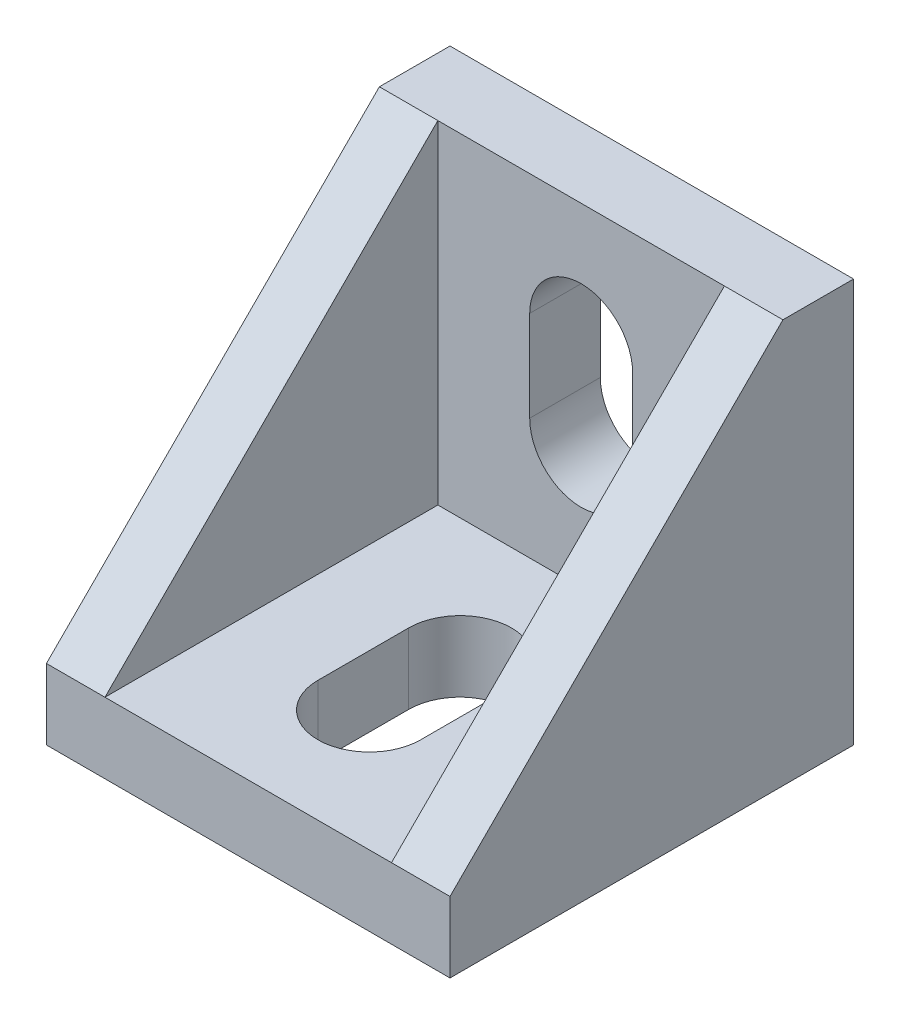
from build123d import *

# Parameters (mm, degrees)
SKETCH1_W          = 20
SKETCH1_H          = 20
EXTRUDE1_DEPTH     = 3.5
SKETCH2_W          = 20
SKETCH2_H          = 3.5
EXTRUDE2_DEPTH     = 16.5
EXTRUDE3_DEPTH     = 2.9
EXTRUDE4_DEPTH     = 2.9
CUT_EXTRUDE1_REACH = 5.5
CUT_EXTRUDE2_REACH = 5.5


with BuildPart() as part:
    # Sketch1 → Extrude1 (new body)
    with BuildSketch(Plane.XY):
        with Locations((10, 10)):
            Rectangle(SKETCH1_W, SKETCH1_H)
    extrude(amount=EXTRUDE1_DEPTH)

    # Sketch2 → Extrude2 (add)
    with BuildSketch(Plane.XY.offset(3.5)):
        with Locations((10, 1.75)):
            Rectangle(SKETCH2_W, SKETCH2_H)
    extrude(amount=EXTRUDE2_DEPTH)

    # Sketch5 → Extrude3 (add)
    with BuildSketch(Plane(origin=(20, 0, 0), x_dir=(0, 0, -1), z_dir=(1, 0, 0))):
        Polygon((-3.5, 20), (-20, 3.5), (-3.5, 3.5), align=None)
    extrude(amount=-EXTRUDE3_DEPTH)

    # Sketch6 → Extrude4 (add)
    with BuildSketch(Plane.ZY):
        Polygon((3.5, 20), (20, 3.5), (3.5, 3.5), align=None)
    extrude(amount=-EXTRUDE4_DEPTH)

    # Sketch7 → Cut-Extrude1 (cut, up to next)
    with BuildSketch(Plane(origin=(0, 3.5, 0), x_dir=(1, 0, 0), z_dir=(0, 1, 0)), mode=Mode.PRIVATE) as cut_extrude1_sk1:
        with BuildLine():
            Line((7.45, -14), (7.45, -9.5))
            ThreePointArc((7.45, -9.5), (10, -6.95), (12.55, -9.5))
            Line((12.55, -9.5), (12.55, -14))
            ThreePointArc((12.55, -14), (10, -16.55), (7.45, -14))
        make_face()
    cut_extrude1_tool1 = extrude(cut_extrude1_sk1.sketch, amount=-CUT_EXTRUDE1_REACH, mode=Mode.PRIVATE) & part.part
    add(cut_extrude1_tool1.solids().sort_by_distance((10, 3.5, 11.75))[0], mode=Mode.SUBTRACT)

    # Sketch8 → Cut-Extrude2 (cut, up to next)
    with BuildSketch(Plane(origin=(0, 0, 3.5), x_dir=(-1, 0, 0), z_dir=(0, 0, 1)), mode=Mode.PRIVATE) as cut_extrude2_sk1:
        with BuildLine():
            Line((-12.55, -14), (-12.55, -9.5))
            ThreePointArc((-12.55, -9.5), (-10, -6.95), (-7.45, -9.5))
            Line((-7.45, -9.5), (-7.45, -14))
            ThreePointArc((-7.45, -14), (-10, -16.55), (-12.55, -14))
        make_face()
    cut_extrude2_tool1 = extrude(cut_extrude2_sk1.sketch, amount=-CUT_EXTRUDE2_REACH, mode=Mode.PRIVATE) & part.part
    add(cut_extrude2_tool1.solids().sort_by_distance((10, 11.75, 3.5))[0], mode=Mode.SUBTRACT)


solid = part.part
